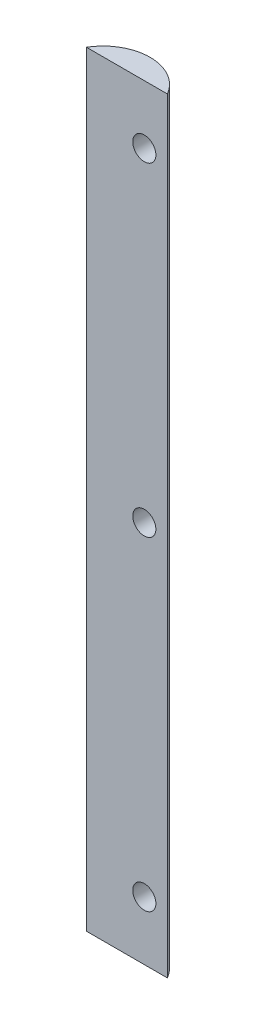
from build123d import *

# Parameters (mm, degrees)
BOSS_EXTRUDE1_START     = -6.35
BOSS_EXTRUDE1_DEPTH     = 209.972402
SKETCH1_R               = 3.175
CUT_EXTRUDE2_DEPTH      = 1
CUT_EXTRUDE2_DEPTH_BACK = 7.35


with BuildPart() as part:
    # Sketch2 → Boss-Extrude1 (new body)
    with BuildSketch(Plane(origin=(0, 0, 0), x_dir=(1, 0, 0), z_dir=(0, 1, 0)).offset(BOSS_EXTRUDE1_START)):
        with BuildLine():
            Line((0, 0), (6.35, 0))
            ThreePointArc((6.35, 0), (-4.7625, 6.35), (-15.875, 0))
            Line((-15.875, 0), (0, 0))
        make_face()
    extrude(amount=BOSS_EXTRUDE1_DEPTH)

    # Sketch1 → Cut-Extrude2 (cut, two sides)
    with BuildSketch(Plane.XY) as cut_extrude2_sk:
        with Locations((0, 187.536328)):
            Circle(SKETCH1_R)
        with Locations((0, 9.736074)):
            Circle(SKETCH1_R)
        with Locations((0, 98.636201)):
            Circle(SKETCH1_R)
    extrude(amount=CUT_EXTRUDE2_DEPTH, mode=Mode.SUBTRACT)
    extrude(cut_extrude2_sk.sketch, amount=-CUT_EXTRUDE2_DEPTH_BACK, mode=Mode.SUBTRACT)


solid = part.part
